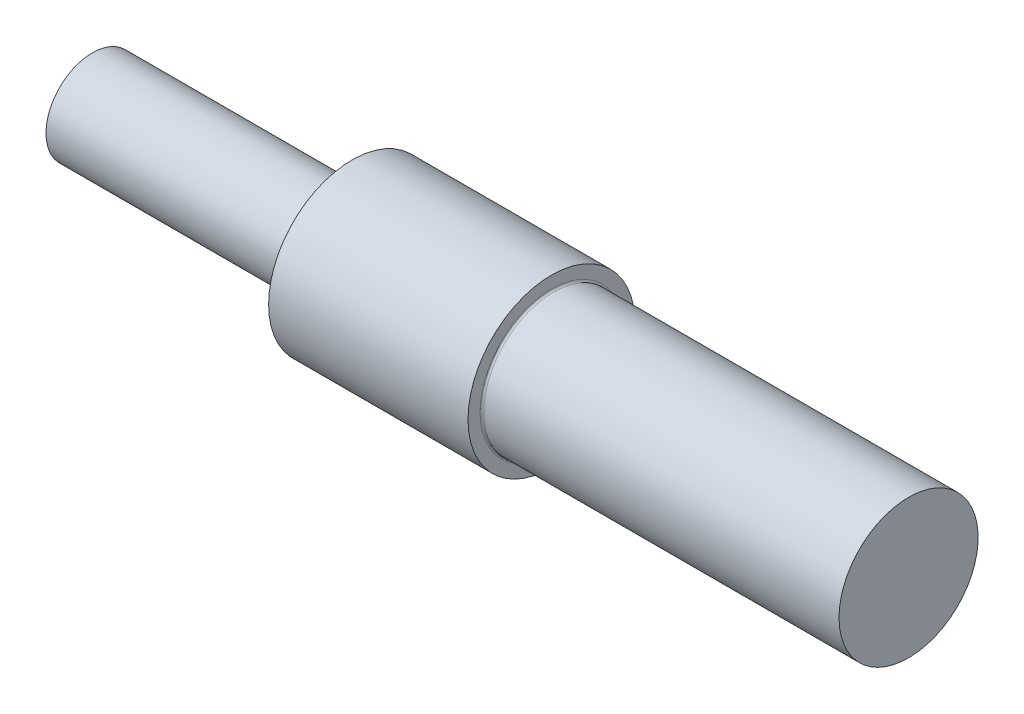
from build123d import *


with BuildPart() as part:
    # Sketch1 → Revolve1 (revolve)
    with BuildSketch(Plane.XY, mode=Mode.PRIVATE) as revolve1_sk:
        with BuildLine():
            Line((-1, 5), (-28, 5))
            Line((-28, 5), (-28, 0))
            Line((-28, 0), (60, 0))
            Line((60, 0), (60, 7.5))
            Line((60, 7.5), (21.7, 7.5))
            ThreePointArc((21.7, 7.5), (21.558578644, 7.558578644), (21.5, 7.7))
            Line((21.5, 7.7), (21.5, 9))
            Line((21.5, 9), (0, 9))
            Line((0, 9), (0, 5))
            ThreePointArc((0, 5), (-0.5, 4.5), (-1, 5))
        make_face()
    revolve(revolve1_sk.sketch.rotate(Axis((-49.812651096, 0, 0), (1, 0, 0)), 90), axis=Axis((-49.812651096, 0, 0), (1, 0, 0)))  # turned: the seam where the file's is


solid = part.part
